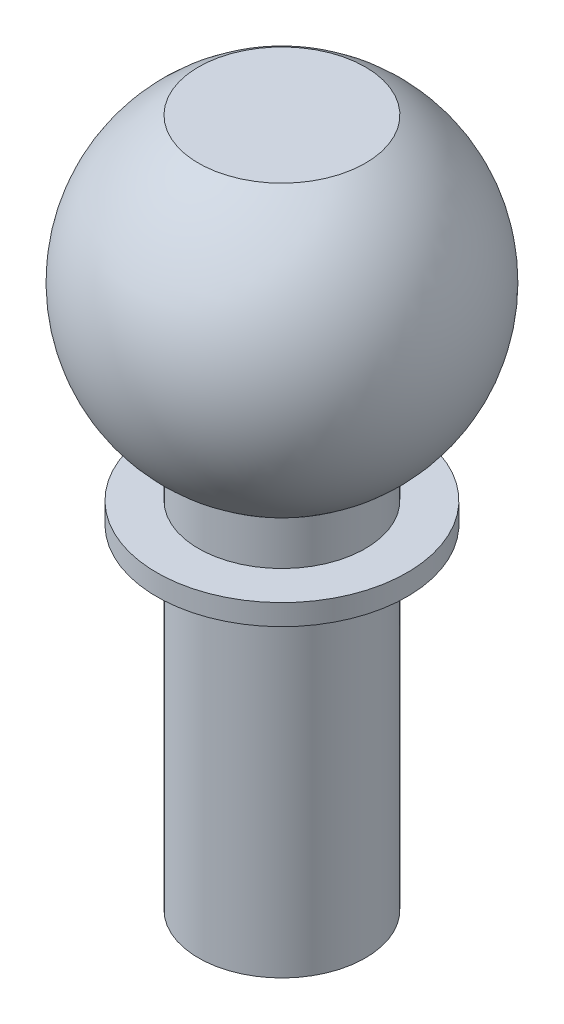
from build123d import *


with BuildPart() as part:
    # Sketch1 → Revolve1 (revolve)
    with BuildSketch(Plane.XY):
        with BuildLine():
            Line((0, 0), (20, 0))
            Line((20, 0), (20, 80))
            Line((20, 80), (30, 80))
            Line((30, 80), (30, 85))
            Line((30, 85), (20, 85))
            Line((20, 85), (20, 95.717967697))
            ThreePointArc((20, 95.717967697), (40, 130.358983849), (20, 165))
            Line((20, 165), (0, 165))
            Line((0, 165), (0, 0))
        make_face()
    revolve(axis=Axis((0, 0, 0), (0, 1, 0)))


solid = part.part
